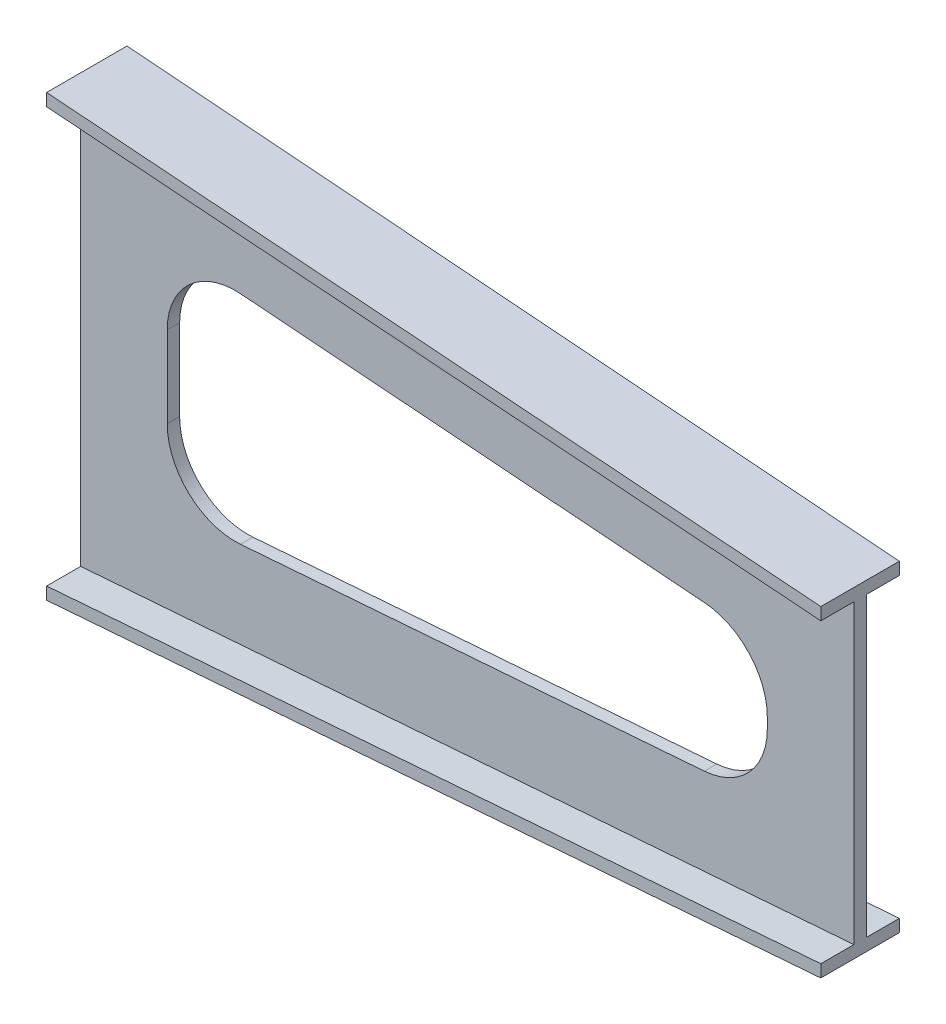
from build123d import *

# Parameters (mm, degrees)
CUT_EXTRUDE1_DEPTH = 76.0000001


with BuildPart() as part:
    # Sketch1 → Loft l2 section 0
    with BuildSketch(Plane(origin=(0, 0, 0), x_dir=(0, 0, -1), z_dir=(1, 0, 0))):
        Polygon((-75, 355.5), (55, 355.5), (55, 335.5), (0, 335.5), (0, -335.5), (55, -335.5), (55, -355.5), (-75, -355.5), (-75, -335.5), (-20, -335.5), (-20, 335.5), (-75, 335.5), align=None)
    # Sketch4 → Loft l2 section 1
    with BuildSketch(Plane(origin=(1250, 0, -1000), x_dir=(0, 0, 1), z_dir=(-1, 0, 0))):
        Polygon((946.5, 260), (1073.5, 260), (1073.5, 240), (1020, 240), (1020, -240), (1073.5, -240), (1073.5, -260), (946.5, -260), (946.5, -240), (1000, -240), (1000, 240), (946.5, 240), align=None)
    loft()

    # Sketch6 → Cut-Extrude1 (cut, through all)
    with BuildSketch(Plane.XY.offset(20)):
        with BuildLine():
            Line((258.379579946, -175.351807385), (1008.379579946, -118.051807385))
            ThreePointArc((1008.379579946, -118.051807385), (1080.690004939, -83.131879682), (1110, -8.371441595))
            Line((1110, -8.371441595), (1110, 8.371441595))
            ThreePointArc((1110, 8.371441595), (1080.690004939, 83.131879682), (1008.379579946, 118.051807385))
            Line((1008.379579946, 118.051807385), (258.379579946, 175.351807385))
            ThreePointArc((258.379579946, 175.351807385), (175.239561913, 146.361446534), (140, 65.671441595))
            Line((140, 65.671441595), (140, -65.671441595))
            ThreePointArc((140, -65.671441595), (175.239561913, -146.361446534), (258.379579946, -175.351807385))
        make_face()
    extrude(amount=-CUT_EXTRUDE1_DEPTH, mode=Mode.SUBTRACT)


solid = part.part
